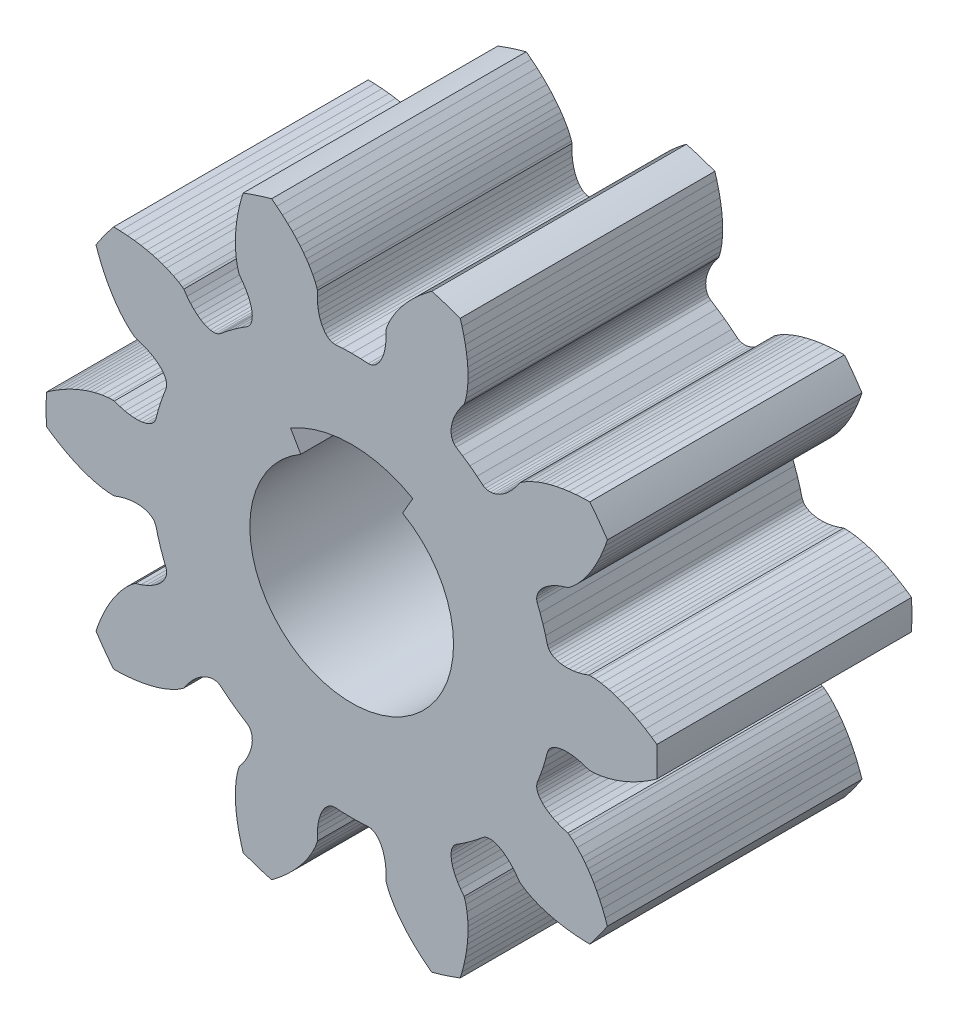
from build123d import *

# Parameters (mm, degrees)
MODEL_R             = 2
BOSS_EXTRUDE1_DEPTH = 5
CUT_EXTRUDE2_DEPTH  = 14


with BuildPart() as part:
    # Model → Boss-Extrude1 (new body)
    with BuildSketch(Plane.XY):
        with BuildLine():
            Line((4.9788314, 3.1648419), (4.9256866, 3.0301363))
            Line((4.9256866, 3.0301363), (4.8697843, 2.9041766))
            Line((4.8697843, 2.9041766), (4.812595, 2.7886499))
            Line((4.812595, 2.7886499), (4.7546103, 2.6829167))
            Line((4.7546103, 2.6829167), (4.6968478, 2.5872761))
            Line((4.6968478, 2.5872761), (4.6384788, 2.4992298))
            Line((4.6384788, 2.4992298), (4.5834943, 2.4233551))
            Line((4.5834943, 2.4233551), (4.5279293, 2.3530853))
            Line((4.5279293, 2.3530853), (4.4290261, 2.2426788))
            Line((4.4290261, 2.2426788), (4.3425918, 2.1609806))
            Line((4.3425918, 2.1609806), (4.2761307, 2.1079684))
            Line((4.2761307, 2.1079684), (4.2450132, 2.0867542))
            Line((4.2450132, 2.0867542), (4.1363837, 2.0539819))
            Line((4.1363837, 2.0539819), (4.0379713, 2.0161386))
            Line((4.0379713, 2.0161386), (3.9500002, 1.9740227))
            Line((3.9500002, 1.9740227), (3.8726379, 1.9284458))
            Line((3.8726379, 1.9284458), (3.8060201, 1.8802194))
            Line((3.8060201, 1.8802194), (3.7501975, 1.8301591))
            Line((3.7501975, 1.8301591), (3.7051951, 1.7790933))
            Line((3.7051951, 1.7790933), (3.6709843, 1.7278222))
            Line((3.6709843, 1.7278222), (3.6474956, 1.6771749))
            Line((3.6474956, 1.6771749), (3.6345958, 1.6279494))
            Line((3.6345958, 1.6279494), (3.6321137, 1.5809311))
            Line((3.6321137, 1.5809311), (3.6433155, 1.5264565))
            Line((3.6433155, 1.5264565), (3.6986142, 1.3866838))
            Line((3.6986142, 1.3866838), (3.7566732, 1.2206171))
            Line((3.7566732, 1.2206171), (3.807314, 1.0521401))
            Line((3.807314, 1.0521401), (3.8447328, 0.9065579))
            Line((3.8447328, 0.9065579), (3.8676897, 0.8559027))
            Line((3.8676897, 0.8559027), (3.8973344, 0.8193231))
            Line((3.8973344, 0.8193231), (3.9367046, 0.7870811))
            Line((3.9367046, 0.7870811), (3.9854771, 0.7599129))
            Line((3.9854771, 0.7599129), (4.0432906, 0.7385423))
            Line((4.0432906, 0.7385423), (4.109714, 0.7236809))
            Line((4.109714, 0.7236809), (4.1843002, 0.7159931))
            Line((4.1843002, 0.7159931), (4.2665418, 0.716134))
            Line((4.2665418, 0.716134), (4.3559187, 0.7247339))
            Line((4.3559187, 0.7247339), (4.4518439, 0.7423696))
            Line((4.4518439, 0.7423696), (4.553705, 0.7695991))
            Line((4.553705, 0.7695991), (4.6608512, 0.8069365))
            Line((4.6608512, 0.8069365), (4.6984951, 0.8080643))
            Line((4.6984951, 0.8080643), (4.7834231, 0.8042414))
            Line((4.7834231, 0.8042414), (4.9013709, 0.7889509))
            Line((4.9013709, 0.7889509), (5.0462806, 0.7577641))
            Line((5.0462806, 0.7577641), (5.1325371, 0.7335749))
            Line((5.1325371, 0.7335749), (5.2216186, 0.7045101))
            Line((5.2216186, 0.7045101), (5.3205924, 0.6675875))
            Line((5.3205924, 0.6675875), (5.4235394, 0.6241646))
            Line((5.4235394, 0.6241646), (5.5325984, 0.5727072))
            Line((5.5325984, 0.5727072), (5.6467704, 0.5128591))
            Line((5.6467704, 0.5128591), (5.7660336, 0.4438142))
            Line((5.7660336, 0.4438142), (5.8882066, 0.3660728))
            Line((5.8882066, 0.3660728), (5.99277823, 0.293578603))
            ThreePointArc((5.99277823, 0.293578603), (5.9999649, 0), (5.99277823, -0.293578603))
            Line((5.99277823, -0.293578603), (5.8882066, -0.3660728))
            Line((5.8882066, -0.3660728), (5.7660336, -0.4438142))
            Line((5.7660336, -0.4438142), (5.6467704, -0.5128591))
            Line((5.6467704, -0.5128591), (5.5325984, -0.5727072))
            Line((5.5325984, -0.5727072), (5.4235394, -0.6241646))
            Line((5.4235394, -0.6241646), (5.3205924, -0.6675875))
            Line((5.3205924, -0.6675875), (5.2216186, -0.7045101))
            Line((5.2216186, -0.7045101), (5.1325371, -0.7335749))
            Line((5.1325371, -0.7335749), (5.0462806, -0.7577641))
            Line((5.0462806, -0.7577641), (4.9013709, -0.7889509))
            Line((4.9013709, -0.7889509), (4.7834231, -0.8042414))
            Line((4.7834231, -0.8042414), (4.6984951, -0.8080643))
            Line((4.6984951, -0.8080643), (4.6608512, -0.8069365))
            Line((4.6608512, -0.8069365), (4.553705, -0.7695991))
            Line((4.553705, -0.7695991), (4.4518439, -0.7423696))
            Line((4.4518439, -0.7423696), (4.3559187, -0.7247339))
            Line((4.3559187, -0.7247339), (4.2665418, -0.716134))
            Line((4.2665418, -0.716134), (4.1843002, -0.7159931))
            Line((4.1843002, -0.7159931), (4.109714, -0.7236809))
            Line((4.109714, -0.7236809), (4.0432906, -0.7385423))
            Line((4.0432906, -0.7385423), (3.9854771, -0.7599129))
            Line((3.9854771, -0.7599129), (3.9367046, -0.7870811))
            Line((3.9367046, -0.7870811), (3.8973344, -0.8193231))
            Line((3.8973344, -0.8193231), (3.8676897, -0.8559027))
            Line((3.8676897, -0.8559027), (3.8447328, -0.9065579))
            Line((3.8447328, -0.9065579), (3.807314, -1.0521401))
            Line((3.807314, -1.0521401), (3.7566732, -1.2206171))
            Line((3.7566732, -1.2206171), (3.6986142, -1.3866838))
            Line((3.6986142, -1.3866838), (3.6433155, -1.5264565))
            Line((3.6433155, -1.5264565), (3.6321137, -1.5809311))
            Line((3.6321137, -1.5809311), (3.6345958, -1.6279494))
            Line((3.6345958, -1.6279494), (3.6474956, -1.6771749))
            Line((3.6474956, -1.6771749), (3.6709843, -1.7278222))
            Line((3.6709843, -1.7278222), (3.7051951, -1.7790933))
            Line((3.7051951, -1.7790933), (3.7501975, -1.8301591))
            Line((3.7501975, -1.8301591), (3.8060201, -1.8802194))
            Line((3.8060201, -1.8802194), (3.8726379, -1.9284458))
            Line((3.8726379, -1.9284458), (3.9500002, -1.9740227))
            Line((3.9500002, -1.9740227), (4.0379713, -2.0161386))
            Line((4.0379713, -2.0161386), (4.1363837, -2.0539819))
            Line((4.1363837, -2.0539819), (4.2450132, -2.0867542))
            Line((4.2450132, -2.0867542), (4.2761307, -2.1079684))
            Line((4.2761307, -2.1079684), (4.3425918, -2.1609806))
            Line((4.3425918, -2.1609806), (4.4290261, -2.2426788))
            Line((4.4290261, -2.2426788), (4.5279293, -2.3530853))
            Line((4.5279293, -2.3530853), (4.5834943, -2.4233551))
            Line((4.5834943, -2.4233551), (4.6384788, -2.4992298))
            Line((4.6384788, -2.4992298), (4.6968478, -2.5872761))
            Line((4.6968478, -2.5872761), (4.7546103, -2.6829167))
            Line((4.7546103, -2.6829167), (4.812595, -2.7886499))
            Line((4.812595, -2.7886499), (4.8697843, -2.9041766))
            Line((4.8697843, -2.9041766), (4.9256866, -3.0301363))
            Line((4.9256866, -3.0301363), (4.9788314, -3.1648419))
            Line((4.9788314, -3.1648419), (5.020820507, -3.284956607))
            ThreePointArc((5.020820507, -3.284956607), (4.854073494, -3.526690876), (4.675698207, -3.759976709))
            Line((4.675698207, -3.759976709), (4.548487, -3.7571601))
            Line((4.548487, -3.7571601), (4.4039518, -3.7482428))
            Line((4.4039518, -3.7482428), (4.2668822, -3.7340001))
            Line((4.2668822, -3.7340001), (4.1393373, -3.7153096))
            Line((4.1393373, -3.7153096), (4.0208608, -3.6928363))
            Line((4.0208608, -3.6928363), (3.9120516, -3.6674554))
            Line((3.9120516, -3.6674554), (3.8102776, -3.639151))
            Line((3.8102776, -3.639151), (3.7211253, -3.6103042))
            Line((3.7211253, -3.6103042), (3.6371242, -3.5791733))
            Line((3.6371242, -3.5791733), (3.5015587, -3.5192282))
            Line((3.5015587, -3.5192282), (3.3971494, -3.4622705))
            Line((3.3971494, -3.4622705), (3.3261941, -3.4154439))
            Line((3.3261941, -3.4154439), (3.2964024, -3.392405))
            Line((3.2964024, -3.392405), (3.2316657, -3.2992194))
            Line((3.2316657, -3.2992194), (3.1652635, -3.2173178))
            Line((3.1652635, -3.2173178), (3.0980244, -3.1466669))
            Line((3.0980244, -3.1466669), (3.0307718, -3.087175))
            Line((3.0307718, -3.087175), (2.9643198, -3.0387205))
            Line((2.9643198, -3.0387205), (2.8994595, -3.0010995))
            Line((2.8994595, -3.0010995), (2.8369865, -2.9740799))
            Line((2.8369865, -2.9740799), (2.7776531, -2.9573872))
            Line((2.7776531, -2.9573872), (2.7222262, -2.9506989))
            Line((2.7222262, -2.9506989), (2.6714237, -2.953642))
            Line((2.6714237, -2.953642), (2.6259397, -2.9658108))
            Line((2.6259397, -2.9658108), (2.5775928, -2.993298))
            Line((2.5775928, -2.993298), (2.4617493, -3.0890823))
            Line((2.4617493, -3.0890823), (2.3217517, -3.1956171))
            Line((2.3217517, -3.1956171), (2.1771695, -3.2958416))
            Line((2.1771695, -3.2958416), (2.0502756, -3.3764164))
            Line((2.0502756, -3.3764164), (2.0091937, -3.413903))
            Line((2.0091937, -3.413903), (1.9835651, -3.4534005))
            Line((1.9835651, -3.4534005), (1.9650672, -3.5008071))
            Line((1.9650672, -3.5008071), (1.9543003, -3.555588))
            Line((1.9543003, -3.555588), (1.951841, -3.6171757))
            Line((1.951841, -3.6171757), (1.9582329, -3.6849406))
            Line((1.9582329, -3.6849406), (1.9739697, -3.7582519))
            Line((1.9739697, -3.7582519), (1.9995179, -3.8364248))
            Line((1.9995179, -3.8364248), (2.0353158, -3.9187698))
            Line((2.0353158, -3.9187698), (2.0817309, -4.0045504))
            Line((2.0817309, -4.0045504), (2.1391045, -4.0930116))
            Line((2.1391045, -4.0930116), (2.2077245, -4.1833758))
            Line((2.2077245, -4.1833758), (2.2204297, -4.2188288))
            Line((2.2204297, -4.2188288), (2.2430381, -4.3007815))
            Line((2.2430381, -4.3007815), (2.2649438, -4.4176815))
            Line((2.2649438, -4.4176815), (2.2800629, -4.565136))
            Line((2.2800629, -4.565136), (2.2837124, -4.6546458))
            Line((2.2837124, -4.6546458), (2.2835978, -4.7483488))
            Line((2.2835978, -4.7483488), (2.279067, -4.8538882))
            Line((2.279067, -4.8538882), (2.2695817, -4.965215))
            Line((2.2695817, -4.965215), (2.2543438, -5.0848375))
            Line((2.2543438, -5.0848375), (2.2327061, -5.2119156))
            Line((2.2327061, -5.2119156), (2.2038948, -5.3466777))
            Line((2.2038948, -5.3466777), (2.1677118, -5.4868946))
            Line((2.1677118, -5.4868946), (2.131080097, -5.608749984))
            ThreePointArc((2.131080097, -5.608749984), (1.854091048, -5.706305666), (1.572660394, -5.790191488))
            Line((1.572660394, -5.790191488), (1.4714, -5.71314))
            Line((1.4714, -5.71314), (1.35971, -5.62097))
            Line((1.35971, -5.62097), (1.25719, -5.52888))
            Line((1.25719, -5.52888), (1.16499, -5.43879))
            Line((1.16499, -5.43879), (1.08235, -5.35097))
            Line((1.08235, -5.35097), (1.00924, -5.26648))
            Line((1.00924, -5.26648), (0.94354, -5.18376))
            Line((0.94354, -5.18376), (0.88837, -5.10802))
            Line((0.88837, -5.10802), (0.83871, -5.03346))
            Line((0.83871, -5.03346), (0.76427, -4.90528))
            Line((0.76427, -4.90528), (0.71328, -4.79783))
            Line((0.71328, -4.79783), (0.6834, -4.71824))
            Line((0.6834, -4.71824), (0.67284, -4.68209))
            Line((0.67284, -4.68209), (0.67524, -4.56865))
            Line((0.67524, -4.56865), (0.66966, -4.46336))
            Line((0.66966, -4.46336), (0.65679, -4.36668))
            Line((0.65679, -4.36668), (0.63735, -4.27902))
            Line((0.63735, -4.27902), (0.61207, -4.20076))
            Line((0.61207, -4.20076), (0.58171, -4.1322))
            Line((0.58171, -4.1322), (0.54705, -4.07362))
            Line((0.54705, -4.07362), (0.50886, -4.02524))
            Line((0.50886, -4.02524), (0.46795, -3.98725))
            Line((0.46795, -3.98725), (0.42512, -3.95977))
            Line((0.42512, -3.95977), (0.38117, -3.94288))
            Line((0.38117, -3.94288), (0.3259, -3.9367))
            Line((0.3259, -3.9367), (0.17588, -3.9461))
            Line((0.17588, -3.9461), (0, -3.95))
            Line((0, -3.95), (-0.17588, -3.9461))
            Line((-0.17588, -3.9461), (-0.3259, -3.9367))
            Line((-0.3259, -3.9367), (-0.38117, -3.94288))
            Line((-0.38117, -3.94288), (-0.42512, -3.95977))
            Line((-0.42512, -3.95977), (-0.46795, -3.98725))
            Line((-0.46795, -3.98725), (-0.50886, -4.02524))
            Line((-0.50886, -4.02524), (-0.54705, -4.07362))
            Line((-0.54705, -4.07362), (-0.58171, -4.1322))
            Line((-0.58171, -4.1322), (-0.61207, -4.20076))
            Line((-0.61207, -4.20076), (-0.63735, -4.27902))
            Line((-0.63735, -4.27902), (-0.65679, -4.36668))
            Line((-0.65679, -4.36668), (-0.66966, -4.46336))
            Line((-0.66966, -4.46336), (-0.67524, -4.56865))
            Line((-0.67524, -4.56865), (-0.67284, -4.68209))
            Line((-0.67284, -4.68209), (-0.6834, -4.71824))
            Line((-0.6834, -4.71824), (-0.71328, -4.79783))
            Line((-0.71328, -4.79783), (-0.76427, -4.90528))
            Line((-0.76427, -4.90528), (-0.83871, -5.03346))
            Line((-0.83871, -5.03346), (-0.88837, -5.10802))
            Line((-0.88837, -5.10802), (-0.94354, -5.18376))
            Line((-0.94354, -5.18376), (-1.00924, -5.26648))
            Line((-1.00924, -5.26648), (-1.08235, -5.35097))
            Line((-1.08235, -5.35097), (-1.16499, -5.43879))
            Line((-1.16499, -5.43879), (-1.25719, -5.52888))
            Line((-1.25719, -5.52888), (-1.35971, -5.62097))
            Line((-1.35971, -5.62097), (-1.4714, -5.71314))
            Line((-1.4714, -5.71314), (-1.572660494, -5.790191488))
            ThreePointArc((-1.572660494, -5.790191488), (-1.854091148, -5.706305666), (-2.131080197, -5.608749984))
            Line((-2.131080197, -5.608749984), (-2.1677118, -5.4868946))
            Line((-2.1677118, -5.4868946), (-2.2038948, -5.3466777))
            Line((-2.2038948, -5.3466777), (-2.2327061, -5.2119156))
            Line((-2.2327061, -5.2119156), (-2.2543438, -5.0848375))
            Line((-2.2543438, -5.0848375), (-2.2695817, -4.965215))
            Line((-2.2695817, -4.965215), (-2.279067, -4.8538882))
            Line((-2.279067, -4.8538882), (-2.2835978, -4.7483488))
            Line((-2.2835978, -4.7483488), (-2.2837124, -4.6546458))
            Line((-2.2837124, -4.6546458), (-2.2800629, -4.565136))
            Line((-2.2800629, -4.565136), (-2.2649438, -4.4176815))
            Line((-2.2649438, -4.4176815), (-2.2430381, -4.3007815))
            Line((-2.2430381, -4.3007815), (-2.2204297, -4.2188288))
            Line((-2.2204297, -4.2188288), (-2.2077245, -4.1833758))
            Line((-2.2077245, -4.1833758), (-2.1391045, -4.0930116))
            Line((-2.1391045, -4.0930116), (-2.0817309, -4.0045504))
            Line((-2.0817309, -4.0045504), (-2.0353158, -3.9187698))
            Line((-2.0353158, -3.9187698), (-1.9995179, -3.8364248))
            Line((-1.9995179, -3.8364248), (-1.9739697, -3.7582519))
            Line((-1.9739697, -3.7582519), (-1.9582329, -3.6849406))
            Line((-1.9582329, -3.6849406), (-1.951841, -3.6171757))
            Line((-1.951841, -3.6171757), (-1.9543003, -3.555588))
            Line((-1.9543003, -3.555588), (-1.9650672, -3.5008071))
            Line((-1.9650672, -3.5008071), (-1.9835651, -3.4534005))
            Line((-1.9835651, -3.4534005), (-2.0091937, -3.413903))
            Line((-2.0091937, -3.413903), (-2.0502756, -3.3764164))
            Line((-2.0502756, -3.3764164), (-2.1771695, -3.2958416))
            Line((-2.1771695, -3.2958416), (-2.3217517, -3.1956171))
            Line((-2.3217517, -3.1956171), (-2.4617493, -3.0890823))
            Line((-2.4617493, -3.0890823), (-2.5775928, -2.993298))
            Line((-2.5775928, -2.993298), (-2.6259397, -2.9658108))
            Line((-2.6259397, -2.9658108), (-2.6714237, -2.953642))
            Line((-2.6714237, -2.953642), (-2.7222262, -2.9506989))
            Line((-2.7222262, -2.9506989), (-2.7776531, -2.9573872))
            Line((-2.7776531, -2.9573872), (-2.8369865, -2.9740799))
            Line((-2.8369865, -2.9740799), (-2.8994595, -3.0010995))
            Line((-2.8994595, -3.0010995), (-2.9643198, -3.0387205))
            Line((-2.9643198, -3.0387205), (-3.0307718, -3.087175))
            Line((-3.0307718, -3.087175), (-3.0980244, -3.1466669))
            Line((-3.0980244, -3.1466669), (-3.1652635, -3.2173178))
            Line((-3.1652635, -3.2173178), (-3.2316657, -3.2992194))
            Line((-3.2316657, -3.2992194), (-3.2964024, -3.392405))
            Line((-3.2964024, -3.392405), (-3.3261941, -3.4154439))
            Line((-3.3261941, -3.4154439), (-3.3971494, -3.4622705))
            Line((-3.3971494, -3.4622705), (-3.5015587, -3.5192282))
            Line((-3.5015587, -3.5192282), (-3.6371242, -3.5791733))
            Line((-3.6371242, -3.5791733), (-3.7211253, -3.6103042))
            Line((-3.7211253, -3.6103042), (-3.8102776, -3.639151))
            Line((-3.8102776, -3.639151), (-3.9120516, -3.6674554))
            Line((-3.9120516, -3.6674554), (-4.0208608, -3.6928363))
            Line((-4.0208608, -3.6928363), (-4.1393373, -3.7153096))
            Line((-4.1393373, -3.7153096), (-4.2668822, -3.7340001))
            Line((-4.2668822, -3.7340001), (-4.4039518, -3.7482428))
            Line((-4.4039518, -3.7482428), (-4.548487, -3.7571601))
            Line((-4.548487, -3.7571601), (-4.675698207, -3.759976709))
            ThreePointArc((-4.675698207, -3.759976709), (-4.854073494, -3.526690876), (-5.020820507, -3.284956607))
            Line((-5.020820507, -3.284956607), (-4.9788314, -3.1648419))
            Line((-4.9788314, -3.1648419), (-4.9256866, -3.0301363))
            Line((-4.9256866, -3.0301363), (-4.8697843, -2.9041766))
            Line((-4.8697843, -2.9041766), (-4.812595, -2.7886499))
            Line((-4.812595, -2.7886499), (-4.7546103, -2.6829167))
            Line((-4.7546103, -2.6829167), (-4.6968478, -2.5872761))
            Line((-4.6968478, -2.5872761), (-4.6384788, -2.4992298))
            Line((-4.6384788, -2.4992298), (-4.5834943, -2.4233551))
            Line((-4.5834943, -2.4233551), (-4.5279293, -2.3530853))
            Line((-4.5279293, -2.3530853), (-4.4290261, -2.2426788))
            Line((-4.4290261, -2.2426788), (-4.3425918, -2.1609806))
            Line((-4.3425918, -2.1609806), (-4.2761307, -2.1079684))
            Line((-4.2761307, -2.1079684), (-4.2450132, -2.0867542))
            Line((-4.2450132, -2.0867542), (-4.1363837, -2.0539819))
            Line((-4.1363837, -2.0539819), (-4.0379713, -2.0161386))
            Line((-4.0379713, -2.0161386), (-3.9500002, -1.9740227))
            Line((-3.9500002, -1.9740227), (-3.8726379, -1.9284458))
            Line((-3.8726379, -1.9284458), (-3.8060201, -1.8802194))
            Line((-3.8060201, -1.8802194), (-3.7501975, -1.8301591))
            Line((-3.7501975, -1.8301591), (-3.7051951, -1.7790933))
            Line((-3.7051951, -1.7790933), (-3.6709843, -1.7278222))
            Line((-3.6709843, -1.7278222), (-3.6474956, -1.6771749))
            Line((-3.6474956, -1.6771749), (-3.6345958, -1.6279494))
            Line((-3.6345958, -1.6279494), (-3.6321137, -1.5809311))
            Line((-3.6321137, -1.5809311), (-3.6433155, -1.5264565))
            Line((-3.6433155, -1.5264565), (-3.6986142, -1.3866838))
            Line((-3.6986142, -1.3866838), (-3.7566732, -1.2206171))
            Line((-3.7566732, -1.2206171), (-3.807314, -1.0521401))
            Line((-3.807314, -1.0521401), (-3.8447328, -0.9065579))
            Line((-3.8447328, -0.9065579), (-3.8676897, -0.8559027))
            Line((-3.8676897, -0.8559027), (-3.8973344, -0.8193231))
            Line((-3.8973344, -0.8193231), (-3.9367046, -0.7870811))
            Line((-3.9367046, -0.7870811), (-3.9854771, -0.7599129))
            Line((-3.9854771, -0.7599129), (-4.0432906, -0.7385423))
            Line((-4.0432906, -0.7385423), (-4.109714, -0.7236809))
            Line((-4.109714, -0.7236809), (-4.1843002, -0.7159931))
            Line((-4.1843002, -0.7159931), (-4.2665418, -0.716134))
            Line((-4.2665418, -0.716134), (-4.3559187, -0.7247339))
            Line((-4.3559187, -0.7247339), (-4.4518439, -0.7423696))
            Line((-4.4518439, -0.7423696), (-4.553705, -0.7695991))
            Line((-4.553705, -0.7695991), (-4.6608512, -0.8069365))
            Line((-4.6608512, -0.8069365), (-4.6984951, -0.8080643))
            Line((-4.6984951, -0.8080643), (-4.7834231, -0.8042414))
            Line((-4.7834231, -0.8042414), (-4.9013709, -0.7889509))
            Line((-4.9013709, -0.7889509), (-5.0462806, -0.7577641))
            Line((-5.0462806, -0.7577641), (-5.1325371, -0.7335749))
            Line((-5.1325371, -0.7335749), (-5.2216186, -0.7045101))
            Line((-5.2216186, -0.7045101), (-5.3205924, -0.6675875))
            Line((-5.3205924, -0.6675875), (-5.4235394, -0.6241646))
            Line((-5.4235394, -0.6241646), (-5.5325984, -0.5727072))
            Line((-5.5325984, -0.5727072), (-5.6467704, -0.5128591))
            Line((-5.6467704, -0.5128591), (-5.7660336, -0.4438142))
            Line((-5.7660336, -0.4438142), (-5.8882066, -0.3660728))
            Line((-5.8882066, -0.3660728), (-5.99277823, -0.293578603))
            ThreePointArc((-5.99277823, -0.293578603), (-5.9999649, 0), (-5.99277823, 0.293578603))
            Line((-5.99277823, 0.293578603), (-5.8882066, 0.3660728))
            Line((-5.8882066, 0.3660728), (-5.7660336, 0.4438142))
            Line((-5.7660336, 0.4438142), (-5.6467704, 0.5128591))
            Line((-5.6467704, 0.5128591), (-5.5325984, 0.5727072))
            Line((-5.5325984, 0.5727072), (-5.4235394, 0.6241646))
            Line((-5.4235394, 0.6241646), (-5.3205924, 0.6675875))
            Line((-5.3205924, 0.6675875), (-5.2216186, 0.7045101))
            Line((-5.2216186, 0.7045101), (-5.1325371, 0.7335749))
            Line((-5.1325371, 0.7335749), (-5.0462806, 0.7577641))
            Line((-5.0462806, 0.7577641), (-4.9013709, 0.7889509))
            Line((-4.9013709, 0.7889509), (-4.7834231, 0.8042414))
            Line((-4.7834231, 0.8042414), (-4.6984951, 0.8080643))
            Line((-4.6984951, 0.8080643), (-4.6608512, 0.8069365))
            Line((-4.6608512, 0.8069365), (-4.553705, 0.7695991))
            Line((-4.553705, 0.7695991), (-4.4518439, 0.7423696))
            Line((-4.4518439, 0.7423696), (-4.3559187, 0.7247339))
            Line((-4.3559187, 0.7247339), (-4.2665418, 0.716134))
            Line((-4.2665418, 0.716134), (-4.1843002, 0.7159931))
            Line((-4.1843002, 0.7159931), (-4.109714, 0.7236809))
            Line((-4.109714, 0.7236809), (-4.0432906, 0.7385423))
            Line((-4.0432906, 0.7385423), (-3.9854771, 0.7599129))
            Line((-3.9854771, 0.7599129), (-3.9367046, 0.7870811))
            Line((-3.9367046, 0.7870811), (-3.8973344, 0.8193231))
            Line((-3.8973344, 0.8193231), (-3.8676897, 0.8559027))
            Line((-3.8676897, 0.8559027), (-3.8447328, 0.9065579))
            Line((-3.8447328, 0.9065579), (-3.807314, 1.0521401))
            Line((-3.807314, 1.0521401), (-3.7566732, 1.2206171))
            Line((-3.7566732, 1.2206171), (-3.6986142, 1.3866838))
            Line((-3.6986142, 1.3866838), (-3.6433155, 1.5264565))
            Line((-3.6433155, 1.5264565), (-3.6321137, 1.5809311))
            Line((-3.6321137, 1.5809311), (-3.6345958, 1.6279494))
            Line((-3.6345958, 1.6279494), (-3.6474956, 1.6771749))
            Line((-3.6474956, 1.6771749), (-3.6709843, 1.7278222))
            Line((-3.6709843, 1.7278222), (-3.7051951, 1.7790933))
            Line((-3.7051951, 1.7790933), (-3.7501975, 1.8301591))
            Line((-3.7501975, 1.8301591), (-3.8060201, 1.8802194))
            Line((-3.8060201, 1.8802194), (-3.8726379, 1.9284458))
            Line((-3.8726379, 1.9284458), (-3.9500002, 1.9740227))
            Line((-3.9500002, 1.9740227), (-4.0379713, 2.0161386))
            Line((-4.0379713, 2.0161386), (-4.1363837, 2.0539819))
            Line((-4.1363837, 2.0539819), (-4.2450132, 2.0867542))
            Line((-4.2450132, 2.0867542), (-4.2761307, 2.1079684))
            Line((-4.2761307, 2.1079684), (-4.3425918, 2.1609806))
            Line((-4.3425918, 2.1609806), (-4.4290261, 2.2426788))
            Line((-4.4290261, 2.2426788), (-4.5279293, 2.3530853))
            Line((-4.5279293, 2.3530853), (-4.5834943, 2.4233551))
            Line((-4.5834943, 2.4233551), (-4.6384788, 2.4992298))
            Line((-4.6384788, 2.4992298), (-4.6968478, 2.5872761))
            Line((-4.6968478, 2.5872761), (-4.7546103, 2.6829167))
            Line((-4.7546103, 2.6829167), (-4.812595, 2.7886499))
            Line((-4.812595, 2.7886499), (-4.8697843, 2.9041766))
            Line((-4.8697843, 2.9041766), (-4.9256866, 3.0301363))
            Line((-4.9256866, 3.0301363), (-4.9788314, 3.1648419))
            Line((-4.9788314, 3.1648419), (-5.020820507, 3.284956607))
            ThreePointArc((-5.020820507, 3.284956607), (-4.854073494, 3.526690876), (-4.675698207, 3.759976709))
            Line((-4.675698207, 3.759976709), (-4.548487, 3.7571601))
            Line((-4.548487, 3.7571601), (-4.4039518, 3.7482428))
            Line((-4.4039518, 3.7482428), (-4.2668822, 3.7340001))
            Line((-4.2668822, 3.7340001), (-4.1393373, 3.7153096))
            Line((-4.1393373, 3.7153096), (-4.0208608, 3.6928363))
            Line((-4.0208608, 3.6928363), (-3.9120516, 3.6674554))
            Line((-3.9120516, 3.6674554), (-3.8102776, 3.639151))
            Line((-3.8102776, 3.639151), (-3.7211253, 3.6103042))
            Line((-3.7211253, 3.6103042), (-3.6371242, 3.5791733))
            Line((-3.6371242, 3.5791733), (-3.5015587, 3.5192282))
            Line((-3.5015587, 3.5192282), (-3.3971494, 3.4622705))
            Line((-3.3971494, 3.4622705), (-3.3261941, 3.4154439))
            Line((-3.3261941, 3.4154439), (-3.2964024, 3.392405))
            Line((-3.2964024, 3.392405), (-3.2316657, 3.2992194))
            Line((-3.2316657, 3.2992194), (-3.1652635, 3.2173178))
            Line((-3.1652635, 3.2173178), (-3.0980244, 3.1466669))
            Line((-3.0980244, 3.1466669), (-3.0307718, 3.087175))
            Line((-3.0307718, 3.087175), (-2.9643198, 3.0387205))
            Line((-2.9643198, 3.0387205), (-2.8994595, 3.0010995))
            Line((-2.8994595, 3.0010995), (-2.8369865, 2.9740799))
            Line((-2.8369865, 2.9740799), (-2.7776531, 2.9573872))
            Line((-2.7776531, 2.9573872), (-2.7222262, 2.9506989))
            Line((-2.7222262, 2.9506989), (-2.6714237, 2.953642))
            Line((-2.6714237, 2.953642), (-2.6259397, 2.9658108))
            Line((-2.6259397, 2.9658108), (-2.5775928, 2.993298))
            Line((-2.5775928, 2.993298), (-2.4617493, 3.0890823))
            Line((-2.4617493, 3.0890823), (-2.3217517, 3.1956171))
            Line((-2.3217517, 3.1956171), (-2.1771695, 3.2958416))
            Line((-2.1771695, 3.2958416), (-2.0502756, 3.3764164))
            Line((-2.0502756, 3.3764164), (-2.0091937, 3.413903))
            Line((-2.0091937, 3.413903), (-1.9835651, 3.4534005))
            Line((-1.9835651, 3.4534005), (-1.9650672, 3.5008071))
            Line((-1.9650672, 3.5008071), (-1.9543003, 3.555588))
            Line((-1.9543003, 3.555588), (-1.951841, 3.6171757))
            Line((-1.951841, 3.6171757), (-1.9582329, 3.6849406))
            Line((-1.9582329, 3.6849406), (-1.9739697, 3.7582519))
            Line((-1.9739697, 3.7582519), (-1.9995179, 3.8364248))
            Line((-1.9995179, 3.8364248), (-2.0353158, 3.9187698))
            Line((-2.0353158, 3.9187698), (-2.0817309, 4.0045504))
            Line((-2.0817309, 4.0045504), (-2.1391045, 4.0930116))
            Line((-2.1391045, 4.0930116), (-2.2077245, 4.1833758))
            Line((-2.2077245, 4.1833758), (-2.2204297, 4.2188288))
            Line((-2.2204297, 4.2188288), (-2.2430381, 4.3007815))
            Line((-2.2430381, 4.3007815), (-2.2649438, 4.4176815))
            Line((-2.2649438, 4.4176815), (-2.2800629, 4.565136))
            Line((-2.2800629, 4.565136), (-2.2837124, 4.6546458))
            Line((-2.2837124, 4.6546458), (-2.2835978, 4.7483488))
            Line((-2.2835978, 4.7483488), (-2.279067, 4.8538882))
            Line((-2.279067, 4.8538882), (-2.2695817, 4.965215))
            Line((-2.2695817, 4.965215), (-2.2543438, 5.0848375))
            Line((-2.2543438, 5.0848375), (-2.2327061, 5.2119156))
            Line((-2.2327061, 5.2119156), (-2.2038948, 5.3466777))
            Line((-2.2038948, 5.3466777), (-2.1677118, 5.4868946))
            Line((-2.1677118, 5.4868946), (-2.131080097, 5.608749984))
            ThreePointArc((-2.131080097, 5.608749984), (-1.854091048, 5.706305666), (-1.572660394, 5.790191488))
            Line((-1.572660394, 5.790191488), (-1.4714, 5.71314))
            Line((-1.4714, 5.71314), (-1.35971, 5.62097))
            Line((-1.35971, 5.62097), (-1.25719, 5.52888))
            Line((-1.25719, 5.52888), (-1.16499, 5.43879))
            Line((-1.16499, 5.43879), (-1.08235, 5.35097))
            Line((-1.08235, 5.35097), (-1.00924, 5.26648))
            Line((-1.00924, 5.26648), (-0.94354, 5.18376))
            Line((-0.94354, 5.18376), (-0.88837, 5.10802))
            Line((-0.88837, 5.10802), (-0.83871, 5.03346))
            Line((-0.83871, 5.03346), (-0.76427, 4.90528))
            Line((-0.76427, 4.90528), (-0.71328, 4.79783))
            Line((-0.71328, 4.79783), (-0.6834, 4.71824))
            Line((-0.6834, 4.71824), (-0.67284, 4.68209))
            Line((-0.67284, 4.68209), (-0.67524, 4.56865))
            Line((-0.67524, 4.56865), (-0.66966, 4.46336))
            Line((-0.66966, 4.46336), (-0.65679, 4.36668))
            Line((-0.65679, 4.36668), (-0.63735, 4.27902))
            Line((-0.63735, 4.27902), (-0.61207, 4.20076))
            Line((-0.61207, 4.20076), (-0.58171, 4.1322))
            Line((-0.58171, 4.1322), (-0.54705, 4.07362))
            Line((-0.54705, 4.07362), (-0.50886, 4.02524))
            Line((-0.50886, 4.02524), (-0.46795, 3.98725))
            Line((-0.46795, 3.98725), (-0.42512, 3.95977))
            Line((-0.42512, 3.95977), (-0.38117, 3.94288))
            Line((-0.38117, 3.94288), (-0.3259, 3.9367))
            Line((-0.3259, 3.9367), (-0.17588, 3.9461))
            Line((-0.17588, 3.9461), (0, 3.95))
            Line((0, 3.95), (0.17588, 3.9461))
            Line((0.17588, 3.9461), (0.3259, 3.9367))
            Line((0.3259, 3.9367), (0.38117, 3.94288))
            Line((0.38117, 3.94288), (0.42512, 3.95977))
            Line((0.42512, 3.95977), (0.46795, 3.98725))
            Line((0.46795, 3.98725), (0.50886, 4.02524))
            Line((0.50886, 4.02524), (0.54705, 4.07362))
            Line((0.54705, 4.07362), (0.58171, 4.1322))
            Line((0.58171, 4.1322), (0.61207, 4.20076))
            Line((0.61207, 4.20076), (0.63735, 4.27902))
            Line((0.63735, 4.27902), (0.65679, 4.36668))
            Line((0.65679, 4.36668), (0.66966, 4.46336))
            Line((0.66966, 4.46336), (0.67524, 4.56865))
            Line((0.67524, 4.56865), (0.67284, 4.68209))
            Line((0.67284, 4.68209), (0.6834, 4.71824))
            Line((0.6834, 4.71824), (0.71328, 4.79783))
            Line((0.71328, 4.79783), (0.76427, 4.90528))
            Line((0.76427, 4.90528), (0.83871, 5.03346))
            Line((0.83871, 5.03346), (0.88837, 5.10802))
            Line((0.88837, 5.10802), (0.94354, 5.18376))
            Line((0.94354, 5.18376), (1.00924, 5.26648))
            Line((1.00924, 5.26648), (1.08235, 5.35097))
            Line((1.08235, 5.35097), (1.16499, 5.43879))
            Line((1.16499, 5.43879), (1.25719, 5.52888))
            Line((1.25719, 5.52888), (1.35971, 5.62097))
            Line((1.35971, 5.62097), (1.4714, 5.71314))
            Line((1.4714, 5.71314), (1.572660494, 5.790191488))
            ThreePointArc((1.572660494, 5.790191488), (1.854091148, 5.706305666), (2.131080197, 5.608749984))
            Line((2.131080197, 5.608749984), (2.1677118, 5.4868946))
            Line((2.1677118, 5.4868946), (2.2038948, 5.3466777))
            Line((2.2038948, 5.3466777), (2.2327061, 5.2119156))
            Line((2.2327061, 5.2119156), (2.2543438, 5.0848375))
            Line((2.2543438, 5.0848375), (2.2695817, 4.965215))
            Line((2.2695817, 4.965215), (2.279067, 4.8538882))
            Line((2.279067, 4.8538882), (2.2835978, 4.7483488))
            Line((2.2835978, 4.7483488), (2.2837124, 4.6546458))
            Line((2.2837124, 4.6546458), (2.2800629, 4.565136))
            Line((2.2800629, 4.565136), (2.2649438, 4.4176815))
            Line((2.2649438, 4.4176815), (2.2430381, 4.3007815))
            Line((2.2430381, 4.3007815), (2.2204297, 4.2188288))
            Line((2.2204297, 4.2188288), (2.2077245, 4.1833758))
            Line((2.2077245, 4.1833758), (2.1391045, 4.0930116))
            Line((2.1391045, 4.0930116), (2.0817309, 4.0045504))
            Line((2.0817309, 4.0045504), (2.0353158, 3.9187698))
            Line((2.0353158, 3.9187698), (1.9995179, 3.8364248))
            Line((1.9995179, 3.8364248), (1.9739697, 3.7582519))
            Line((1.9739697, 3.7582519), (1.9582329, 3.6849406))
            Line((1.9582329, 3.6849406), (1.951841, 3.6171757))
            Line((1.951841, 3.6171757), (1.9543003, 3.555588))
            Line((1.9543003, 3.555588), (1.9650672, 3.5008071))
            Line((1.9650672, 3.5008071), (1.9835651, 3.4534005))
            Line((1.9835651, 3.4534005), (2.0091937, 3.413903))
            Line((2.0091937, 3.413903), (2.0502756, 3.3764164))
            Line((2.0502756, 3.3764164), (2.1771695, 3.2958416))
            Line((2.1771695, 3.2958416), (2.3217517, 3.1956171))
            Line((2.3217517, 3.1956171), (2.4617493, 3.0890823))
            Line((2.4617493, 3.0890823), (2.5775928, 2.993298))
            Line((2.5775928, 2.993298), (2.6259397, 2.9658108))
            Line((2.6259397, 2.9658108), (2.6714237, 2.953642))
            Line((2.6714237, 2.953642), (2.7222262, 2.9506989))
            Line((2.7222262, 2.9506989), (2.7776531, 2.9573872))
            Line((2.7776531, 2.9573872), (2.8369865, 2.9740799))
            Line((2.8369865, 2.9740799), (2.8994595, 3.0010995))
            Line((2.8994595, 3.0010995), (2.9643198, 3.0387205))
            Line((2.9643198, 3.0387205), (3.0307718, 3.087175))
            Line((3.0307718, 3.087175), (3.0980244, 3.1466669))
            Line((3.0980244, 3.1466669), (3.1652635, 3.2173178))
            Line((3.1652635, 3.2173178), (3.2316657, 3.2992194))
            Line((3.2316657, 3.2992194), (3.2964024, 3.392405))
            Line((3.2964024, 3.392405), (3.3261941, 3.4154439))
            Line((3.3261941, 3.4154439), (3.3971494, 3.4622705))
            Line((3.3971494, 3.4622705), (3.5015587, 3.5192282))
            Line((3.5015587, 3.5192282), (3.6371242, 3.5791733))
            Line((3.6371242, 3.5791733), (3.7211253, 3.6103042))
            Line((3.7211253, 3.6103042), (3.8102776, 3.639151))
            Line((3.8102776, 3.639151), (3.9120516, 3.6674554))
            Line((3.9120516, 3.6674554), (4.0208608, 3.6928363))
            Line((4.0208608, 3.6928363), (4.1393373, 3.7153096))
            Line((4.1393373, 3.7153096), (4.2668822, 3.7340001))
            Line((4.2668822, 3.7340001), (4.4039518, 3.7482428))
            Line((4.4039518, 3.7482428), (4.548487, 3.7571601))
            Line((4.548487, 3.7571601), (4.675698207, 3.759976709))
            ThreePointArc((4.675698207, 3.759976709), (4.854073494, 3.526690876), (5.020820507, 3.284956607))
            Line((5.020820507, 3.284956607), (4.9788314, 3.1648419))
        make_face()
        Circle(MODEL_R, mode=Mode.SUBTRACT)
    extrude(amount=BOSS_EXTRUDE1_DEPTH)

    # Sketch2 → Cut-Extrude2 (cut)
    with BuildSketch(Plane.XY.offset(5)):
        with BuildLine():
            Line((0, 0), (-1.2, 2.078460969))
            ThreePointArc((-1.2, 2.078460969), (0, 2.4), (1.2, 2.078460969))
            Line((1.2, 2.078460969), (0, 0))
        make_face()
    extrude(amount=-CUT_EXTRUDE2_DEPTH, mode=Mode.SUBTRACT)


solid = part.part
